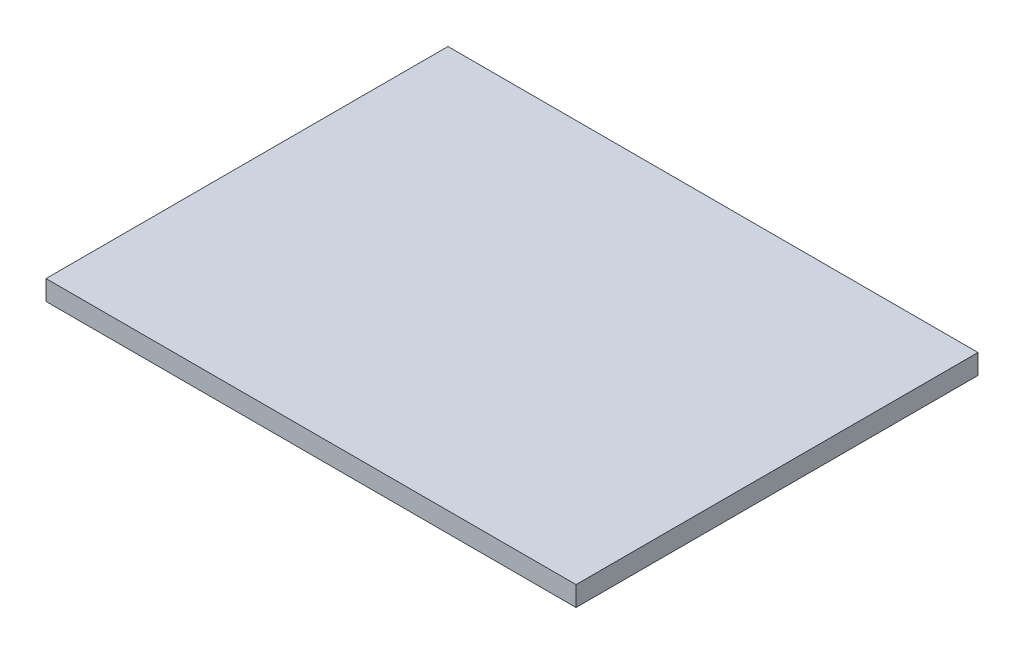
from build123d import *

# Parameters (mm, degrees)
SKETCH1_W           = 480
SKETCH1_H           = 364
BOSS_EXTRUDE1_DEPTH = 18


with BuildPart() as part:
    # Sketch1 → Boss-Extrude1 (new body)
    with BuildSketch(Plane(origin=(0, 0, 0), x_dir=(1, 0, 0), z_dir=(0, 1, 0))):
        with Locations((201.575632918, 164.94428604)):
            Rectangle(SKETCH1_W, SKETCH1_H)
    extrude(amount=BOSS_EXTRUDE1_DEPTH)


solid = part.part
